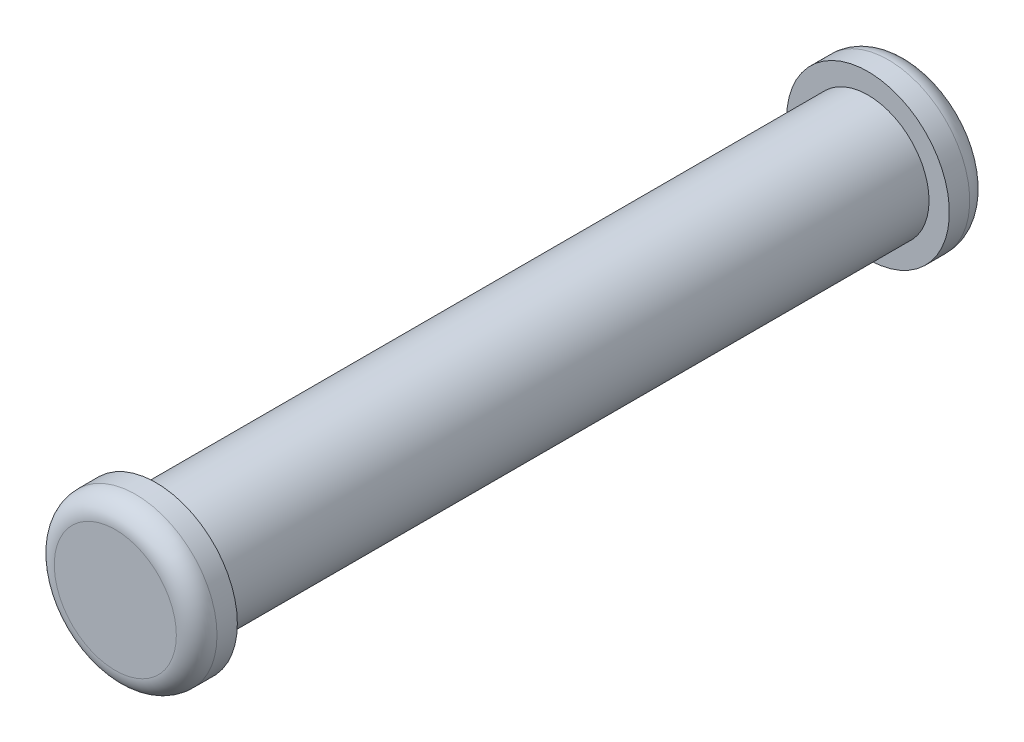
from build123d import *

# Parameters (mm, degrees)
SKETCH1_R           = 1.5
BOSS_EXTRUDE1_DEPTH = 17.5
SKETCH2_R           = 2
BOSS_EXTRUDE2_DEPTH = 1
SKETCH3_R           = 2
BOSS_EXTRUDE3_DEPTH = 1
FILLET1_R           = 0.5


with BuildPart() as part:
    # Sketch1 → Boss-Extrude1 (new body)
    with BuildSketch(Plane.XY):
        Circle(SKETCH1_R)
    extrude(amount=BOSS_EXTRUDE1_DEPTH)

    # Sketch2 → Boss-Extrude2 (add)
    with BuildSketch(Plane(origin=(0, 0, 0), x_dir=(-1, 0, 0), z_dir=(0, 0, -1))):
        Circle(SKETCH2_R)
    extrude(amount=BOSS_EXTRUDE2_DEPTH)

    # Sketch3 → Boss-Extrude3 (add)
    with BuildSketch(Plane.XY.offset(17.5)):
        Circle(SKETCH3_R)
    extrude(amount=BOSS_EXTRUDE3_DEPTH)

    # Fillet1
    fillet1_edges = [part.edges().sort_by_distance(p)[0] for p in [
        (-2, 0, 18.5),
        (2, 0, -1),
    ]]
    fillet(fillet1_edges, radius=FILLET1_R)


solid = part.part
